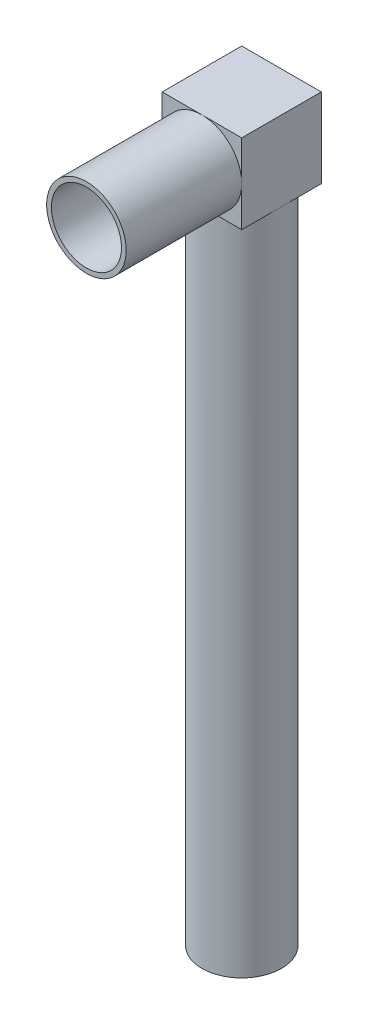
from build123d import *

# Parameters (mm, degrees)
SKETCH1_R           = 21.1
SKETCH1_R_2         = 18.6
BOSS_EXTRUDE4_DEPTH = 58.8
SKETCH4_R           = 21.1
BOSS_EXTRUDE5_DEPTH = 2.5
SKETCH12_W          = 42.2
SKETCH12_H          = 42.2
BOSS_EXTRUDE6_DEPTH = 42.2
SKETCH13_R          = 21.1
BOSS_EXTRUDE7_DEPTH = 350
CUT_EXTRUDE1_DEPTH  = 21.5
SKETCH15_R          = 3
CUT_EXTRUDE2_DEPTH  = 9.5
SKETCH16_R          = 6.025
CUT_EXTRUDE3_DEPTH  = 6.2
SKETCH17_W          = 37.2
SKETCH17_H          = 37.2
CUT_EXTRUDE4_DEPTH  = 39.7
SKETCH18_R          = 15
CUT_EXTRUDE5_DEPTH  = 5
SKETCH19_R          = 1.827460326
CUT_EXTRUDE6_DEPTH  = 2.5
SKETCH23_R          = 17.945895708
CUT_EXTRUDE7_DEPTH  = 2.5


with BuildPart() as part:
    # Sketch1 → Boss-Extrude4 (new body)
    with BuildSketch(Plane.XY):
        Circle(SKETCH1_R)
        Circle(SKETCH1_R_2, mode=Mode.SUBTRACT)
    extrude(amount=BOSS_EXTRUDE4_DEPTH)

    # Sketch4 → Boss-Extrude5 (add)
    with BuildSketch(Plane(origin=(0, 0, 0), x_dir=(-1, 0, 0), z_dir=(0, 0, -1))):
        Circle(SKETCH4_R)
    extrude(amount=BOSS_EXTRUDE5_DEPTH)

    # Sketch12 → Boss-Extrude6 (add)
    with BuildSketch(Plane(origin=(0, 0, -2.5), x_dir=(-1, 0, 0), z_dir=(0, 0, -1))):
        Rectangle(SKETCH12_W, SKETCH12_H)
    extrude(amount=BOSS_EXTRUDE6_DEPTH)

    # Sketch13 → Boss-Extrude7 (add)
    with BuildSketch(Plane(origin=(0, -21.1, 0), x_dir=(-1, 0, 0), z_dir=(0, -1, 0))):
        with Locations((0, 23.6)):
            Circle(SKETCH13_R)
    extrude(amount=BOSS_EXTRUDE7_DEPTH)

    # Sketch14 → Cut-Extrude1 (cut)
    with BuildSketch(Plane(origin=(0, -371.1, 0), x_dir=(-1, 0, 0), z_dir=(0, -1, 0))):
        with BuildLine():
            Line((-1.68529671, 21.1), (1.68529671, 21.1))
            ThreePointArc((1.68529671, 21.1), (0, 26.615), (-1.68529671, 21.1))
        make_face()
    extrude(amount=-CUT_EXTRUDE1_DEPTH, mode=Mode.SUBTRACT)

    # Sketch15 → Cut-Extrude2 (cut)
    with BuildSketch(Plane(origin=(0, -371.1, 0), x_dir=(-1, 0, 0), z_dir=(0, -1, 0))):
        with Locations((0, 23.6)):
            Circle(SKETCH15_R)
    extrude(amount=-CUT_EXTRUDE2_DEPTH, mode=Mode.SUBTRACT)

    # Sketch16 → Cut-Extrude3 (cut)
    with BuildSketch(Plane(origin=(0, -371.1, 0), x_dir=(-1, 0, 0), z_dir=(0, -1, 0))):
        with Locations((0, 23.6)):
            Circle(SKETCH16_R)
    extrude(amount=-CUT_EXTRUDE3_DEPTH, mode=Mode.SUBTRACT)

    # Sketch17 → Cut-Extrude4 (cut)
    with BuildSketch(Plane(origin=(0, 0, -44.7), x_dir=(-1, 0, 0), z_dir=(0, 0, -1))):
        Rectangle(SKETCH17_W, SKETCH17_H)
    extrude(amount=-CUT_EXTRUDE4_DEPTH, mode=Mode.SUBTRACT)

    # Sketch18 → Cut-Extrude5 (cut)
    with BuildSketch(Plane.XY):
        Circle(SKETCH18_R)
    extrude(amount=-CUT_EXTRUDE5_DEPTH, mode=Mode.SUBTRACT)

    # Sketch19 → Cut-Extrude6 (cut)
    with BuildSketch(Plane(origin=(0, -21.1, 0), x_dir=(-1, 0, 0), z_dir=(0, -1, 0))):
        with Locations((-16.772539674, 40.372539674)):
            Circle(SKETCH19_R)
    extrude(amount=-CUT_EXTRUDE6_DEPTH, mode=Mode.SUBTRACT)

    # Sketch23 → Cut-Extrude7 (cut)
    with BuildSketch(Plane(origin=(0, -21.1, 0), x_dir=(-1, 0, 0), z_dir=(0, -1, 0))):
        with Locations((-0.654104292, 23.6)):
            Circle(SKETCH23_R)
    extrude(amount=-CUT_EXTRUDE7_DEPTH, mode=Mode.SUBTRACT)


solid = part.part
